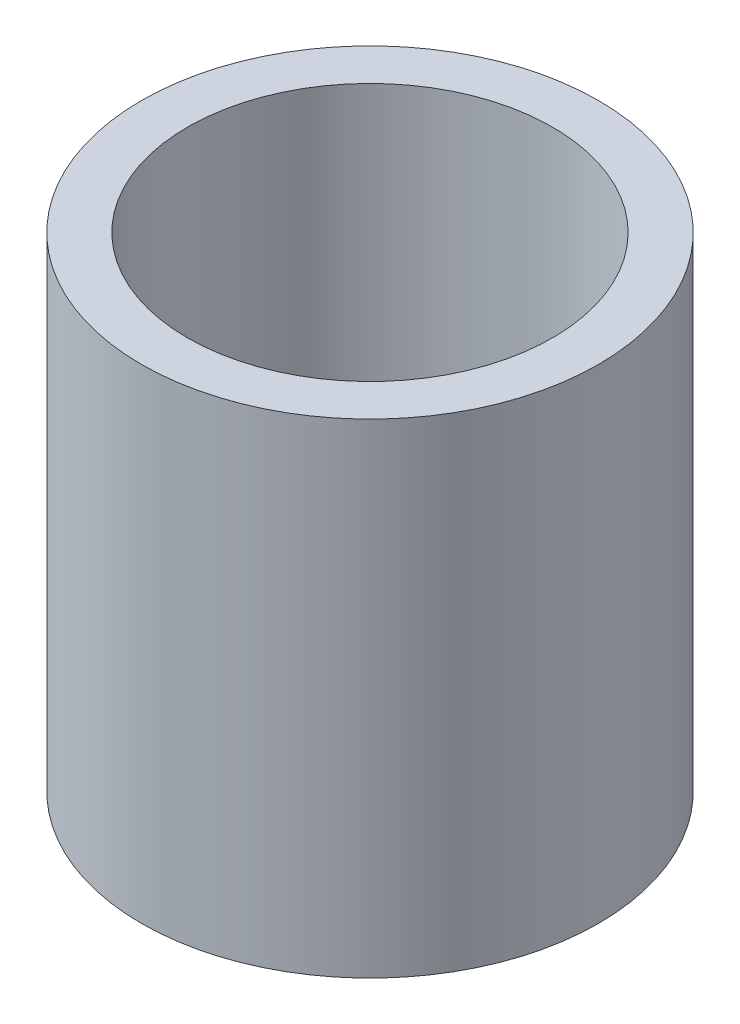
from build123d import *

# Parameters (mm, degrees)
SKETCH1_R           = 3.9751
SKETCH1_R_2         = 3.175
BOSS_EXTRUDE1_DEPTH = 8.4201
SKETCH2_R           = 3.9751
BOSS_EXTRUDE2_DEPTH = 3.7846


with BuildPart() as part:
    # Sketch1 → Boss-Extrude1 (new body)
    with BuildSketch(Plane(origin=(0, 0, 0), x_dir=(1, 0, 0), z_dir=(0, 1, 0))):
        Circle(SKETCH1_R)
        Circle(SKETCH1_R_2, mode=Mode.SUBTRACT)
    extrude(amount=BOSS_EXTRUDE1_DEPTH)

    # Sketch2 → Boss-Extrude2 (add)
    with BuildSketch(Plane(origin=(0, 3.7846, 0), x_dir=(1, 0, 0), z_dir=(0, 1, 0))):
        Circle(SKETCH2_R)
    extrude(amount=-BOSS_EXTRUDE2_DEPTH)


solid = part.part
